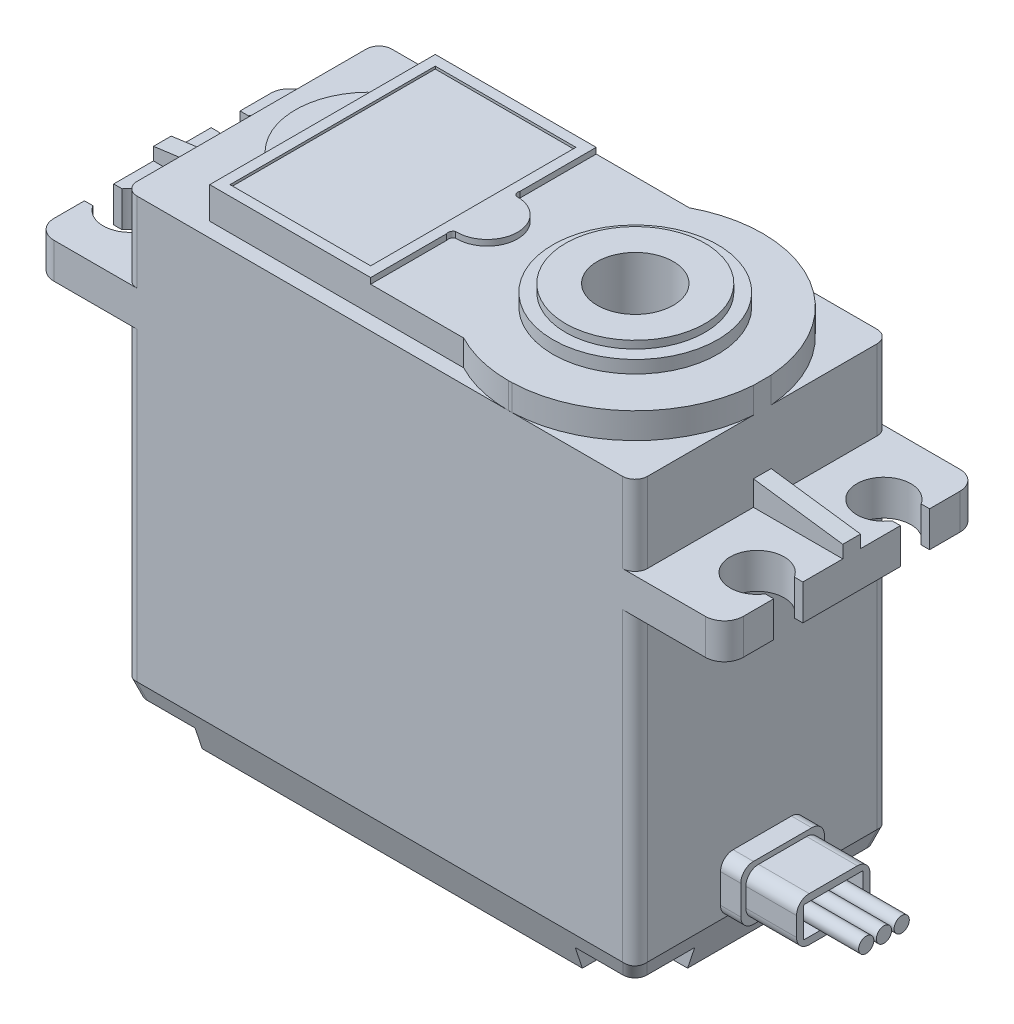
from build123d import *

# Parameters (mm, degrees)
Y_KSEKLIK_EKSTR_ZYON1_DEPTH      = 20.1
Y_KSEKLIK_EKSTR_ZYON2_DEPTH      = 0.7
Y_KSEKLIK_EKSTR_ZYON2_DEPTH_BACK = 0.7
KES_EKSTR_ZYON2_DEPTH            = 50
RADYUS1_R                        = 1.5
RADYUS2_R                        = 1
KES_EKSTR_ZYON4_DEPTH            = 2.5
KES_EKSTR_ZYON6_DEPTH            = 0.4
KES_EKSTR_ZYON7_DEPTH            = 0.46
KES_EKSTR_ZYON8_DEPTH            = 2.5
IZIM10_W                         = 9
IZIM10_H                         = 2.5
KES_EKSTR_ZYON9_DEPTH            = 0.005
IZIM11_W                         = 11.1
IZIM11_H                         = 16.2
KES_EKSTR_ZYON10_DEPTH           = 0.2
IZIM12_R                         = 6.5
IZIM12_R_2                       = 5.5
Y_KSEKLIK_EKSTR_ZYON3_DEPTH      = 1
IZIM13_R                         = 5.5
Y_KSEKLIK_EKSTR_ZYON4_DEPTH      = 1.6
IZIM14_R                         = 3
KES_EKSTR_ZYON11_DEPTH           = 10
KES_EKSTR_ZYON12_DEPTH           = 50
KES_EKSTR_ZYON13_DEPTH           = 50
RADYUS3_R                        = 1
KES_EKSTR_ZYON14_DEPTH           = 1.7
IZIM20_R                         = 1.35
KES_EKSTR_ZYON15_DEPTH           = 32
IZIM21_W                         = 6.6
IZIM21_H                         = 4.3
Y_KSEKLIK_EKSTR_ZYON5_DEPTH      = 1.6
RADYUS4_R                        = 1
IZIM22_W                         = 5.8
IZIM22_H                         = 3.5
Y_KSEKLIK_EKSTR_ZYON6_DEPTH      = 4
RADYUS6_R                        = 1
IZIM23_W                         = 4.7
IZIM23_H                         = 2.4
KES_EKSTR_ZYON17_DEPTH           = 4
RADYUS7_R                        = 0.1
IZIM24_R                         = 0.6
Y_KSEKLIK_EKSTR_ZYON7_DEPTH      = 8


with BuildPart() as part:
    # Çizim1 → Yükseklik-Ekstrüzyon1 (new body)
    with BuildSketch(Plane.XY):
        Polygon((-48.759292093, -35.698320222), (-8.459292093, -35.698320222), (-8.459292093, -8.598320222), (-1.409292093, -8.598320222), (-1.409292093, -5.798320222), (-8.459292093, -5.798320222), (-8.459292093, 3.001679778), (-48.759292093, 3.001679778), (-48.759292093, -5.798320222), (-55.809292093, -5.798320222), (-55.809292093, -8.598320222), (-48.759292093, -8.598320222), align=None)
    extrude(amount=Y_KSEKLIK_EKSTR_ZYON1_DEPTH)

    # Çizim3 → Yükseklik-Ekstrüzyon2 (add, two sides)
    with BuildSketch(Plane.XY.offset(10.05)) as y_kseklik_ekstr_zyon2_sk:
        Polygon((-55.809292093, -5.798320222), (-48.759292093, -5.798320222), (-48.759292093, -3.848320222), (-55.809292093, -4.798320222), align=None)
        Polygon((-8.459292093, -5.798320222), (-1.409292093, -5.798320222), (-1.409292093, -4.798320222), (-8.459292093, -3.848320222), align=None)
    extrude(amount=Y_KSEKLIK_EKSTR_ZYON2_DEPTH)
    extrude(y_kseklik_ekstr_zyon2_sk.sketch, amount=-Y_KSEKLIK_EKSTR_ZYON2_DEPTH_BACK)

    # Çizim4 → Kes-Ekstrüzyon2 (cut)
    with BuildSketch(Plane(origin=(0, 3.001679778, 0), x_dir=(1, 0, 0), z_dir=(0, 1, 0))):
        with BuildLine():
            Line((-55.809292093, -16.2), (-55.146292093, -16.2))
            ThreePointArc((-55.146292093, -16.2), (-51.225748416, -15.04637383), (-55.146292093, -13.892747659))
            Line((-55.146292093, -13.892747659), (-55.809292093, -13.892747659))
            Line((-55.809292093, -13.892747659), (-55.809292093, -16.2))
        make_face()
        with BuildLine():
            Line((-55.809292093, -3.916330706), (-55.146292093, -3.916330706))
            ThreePointArc((-55.146292093, -3.916330706), (-51.218205988, -5.058165353), (-55.146292093, -6.2))
            Line((-55.146292093, -6.2), (-55.809292093, -6.2))
            Line((-55.809292093, -6.2), (-55.809292093, -3.916330706))
        make_face()
        with BuildLine():
            Line((-1.409292093, -6.2), (-2.072292093, -6.2))
            ThreePointArc((-2.072292093, -6.2), (-5.995166879, -5.05), (-2.072292093, -3.9))
            Line((-2.072292093, -3.9), (-1.409292093, -3.9))
            Line((-1.409292093, -3.9), (-1.409292093, -6.2))
        make_face()
        with BuildLine():
            Line((-1.409292093, -13.902170696), (-2.072292093, -13.902170696))
            ThreePointArc((-2.072292093, -13.902170696), (-5.995862588, -15.051085348), (-2.072292093, -16.2))
            Line((-2.072292093, -16.2), (-1.409292093, -16.2))
            Line((-1.409292093, -16.2), (-1.409292093, -13.902170696))
        make_face()
    extrude(amount=-KES_EKSTR_ZYON2_DEPTH, mode=Mode.SUBTRACT)

    # Radyus1
    radyus1_edges = [part.edges().sort_by_distance(p)[0] for p in [
        (-1.409292093, -7.198320222, 20.1),
        (-55.809292093, -7.198320222, 0),
        (-1.409292093, -7.198320222, 0),
        (-55.809292093, -7.198320222, 20.1),
    ]]
    fillet(radyus1_edges, radius=RADYUS1_R)

    # Radyus2
    radyus2_edges = [part.edges().sort_by_distance(p)[0] for p in [
        (-48.759292093, -22.148320222, 0),
        (-48.759292093, -1.398320222, 0),
        (-8.459292093, -1.398320222, 0),
        (-8.459292093, -22.148320222, 0),
        (-8.459292093, -1.398320222, 20.1),
        (-48.759292093, -1.398320222, 20.1),
        (-48.759292093, -22.148320222, 20.1),
        (-8.459292093, -22.148320222, 20.1),
    ]]
    fillet(radyus2_edges, radius=RADYUS2_R)

    # Çizim5 → Kes-Ekstrüzyon4 (cut)
    with BuildSketch(Plane(origin=(0, 3.001679778, 0), x_dir=(1, 0, 0), z_dir=(0, 1, 0))):
        with BuildLine():
            ThreePointArc((-23.127535874, -1.15), (-20.863195169, -0.291734273), (-18.459292093, 0))
            Line((-18.459292093, 0), (-47.759292093, 0))
            ThreePointArc((-47.759292093, 0), (-48.466398874, -0.292893219), (-48.759292093, -1))
            Line((-48.759292093, -1), (-48.759292093, -19.1))
            ThreePointArc((-48.759292093, -19.1), (-48.466398874, -19.807106781), (-47.759292093, -20.1))
            Line((-47.759292093, -20.1), (-18.459292093, -20.1))
            ThreePointArc((-18.459292093, -20.1), (-20.863195169, -19.808265727), (-23.127535874, -18.95))
            Line((-23.127535874, -18.95), (-43.170310905, -18.95))
            Line((-43.170310905, -18.95), (-43.170310905, -14.54))
            ThreePointArc((-43.170310905, -14.54), (-45.305060631, -10.05), (-43.170310905, -5.56))
            Line((-43.170310905, -5.56), (-43.170310905, -1.15))
            Line((-43.170310905, -1.15), (-23.127535874, -1.15))
        make_face()
    extrude(amount=-KES_EKSTR_ZYON4_DEPTH, mode=Mode.SUBTRACT)

    # Çizim7 → Kes-Ekstrüzyon6 (cut)
    with BuildSketch(Plane(origin=(0, 3.001679778, 0), x_dir=(1, 0, 0), z_dir=(0, 1, 0))):
        with BuildLine():
            Line((-43.170310905, -5.56), (-43.170310905, -14.54))
            ThreePointArc((-43.170310905, -14.54), (-45.305060631, -10.05), (-43.170310905, -5.56))
        make_face()
    extrude(amount=-KES_EKSTR_ZYON6_DEPTH, mode=Mode.SUBTRACT)

    # Çizim8 → Kes-Ekstrüzyon7 (cut)
    with BuildSketch(Plane(origin=(0, 3.001679778, 0), x_dir=(1, 0, 0), z_dir=(0, 1, 0))):
        with BuildLine():
            Line((-30.470310905, -1.15), (-23.127535874, -1.15))
            ThreePointArc((-23.127535874, -1.15), (-8.409292093, -10.05), (-23.127535874, -18.95))
            Line((-23.127535874, -18.95), (-30.470310905, -18.95))
            Line((-30.470310905, -18.95), (-30.470310905, -12.945))
            ThreePointArc((-30.470310905, -12.945), (-30.47115449, -12.654263301), (-30.266169104, -12.448084904))
            ThreePointArc((-30.266169104, -12.448084904), (-27.770310905, -10.05), (-30.266169104, -7.651915096))
            ThreePointArc((-30.266169104, -7.651915096), (-30.47115449, -7.445736699), (-30.470310905, -7.155))
            Line((-30.470310905, -7.155), (-30.470310905, -1.15))
        make_face()
    extrude(amount=-KES_EKSTR_ZYON7_DEPTH, mode=Mode.SUBTRACT)

    # Çizim9 → Kes-Ekstrüzyon8 (cut)
    with BuildSketch(Plane(origin=(0, 3.001679778, 0), x_dir=(1, 0, 0), z_dir=(0, 1, 0))):
        with BuildLine():
            Line((-18.459292093, 0), (-8.459292093, 0))
            Line((-8.459292093, 0), (-8.459292093, -9.35))
            ThreePointArc((-8.459292093, -9.35), (-11.621052025, -2.708967842), (-18.459292093, 0))
        make_face()
        with BuildLine():
            Line((-8.459292093, -20.099934818), (-8.459292093, -10.749934818))
            ThreePointArc((-8.459292093, -10.749934818), (-11.621052025, -17.390966976), (-18.459292093, -20.099934818))
            Line((-18.459292093, -20.099934818), (-8.459292093, -20.099934818))
        make_face()
    extrude(amount=-KES_EKSTR_ZYON8_DEPTH, mode=Mode.SUBTRACT)

    # Çizim10 → Kes-Ekstrüzyon9 (cut)
    with BuildSketch(Plane.XY.offset(20.1)):
        with Locations((-13.959292093, 1.751679778)):
            Rectangle(IZIM10_W, IZIM10_H)
    extrude(amount=-KES_EKSTR_ZYON9_DEPTH, mode=Mode.SUBTRACT)

    # Çizim11 → Kes-Ekstrüzyon10 (cut)
    with BuildSketch(Plane(origin=(0, 3.001679778, 0), x_dir=(1, 0, 0), z_dir=(0, 1, 0))):
        with Locations((-36.820310905, -10.05)):
            Rectangle(IZIM11_W, IZIM11_H)
    extrude(amount=-KES_EKSTR_ZYON10_DEPTH, mode=Mode.SUBTRACT)

    # Çizim12 → Yükseklik-Ekstrüzyon3 (add)
    with BuildSketch(Plane(origin=(0, 2.541679778, 0), x_dir=(1, 0, 0), z_dir=(0, 1, 0))):
        with Locations((-18.48488662, -10.049967409)):
            Circle(IZIM12_R)
        with Locations((-18.48488662, -10.049967409)):
            Circle(IZIM12_R_2, mode=Mode.SUBTRACT)
    extrude(amount=Y_KSEKLIK_EKSTR_ZYON3_DEPTH)

    # Çizim13 → Yükseklik-Ekstrüzyon4 (add)
    with BuildSketch(Plane(origin=(0, 2.541679778, 0), x_dir=(1, 0, 0), z_dir=(0, 1, 0))):
        with Locations((-18.48488662, -10.049967409)):
            Circle(IZIM13_R)
    extrude(amount=Y_KSEKLIK_EKSTR_ZYON4_DEPTH)

    # Çizim14 → Kes-Ekstrüzyon11 (cut)
    with BuildSketch(Plane(origin=(0, 4.141679778, 0), x_dir=(1, 0, 0), z_dir=(0, 1, 0))):
        with Locations((-18.48488662, -10.049967409)):
            Circle(IZIM14_R)
    extrude(amount=-KES_EKSTR_ZYON11_DEPTH, mode=Mode.SUBTRACT)

    # Çizim15 → Kes-Ekstrüzyon12 (cut)
    with BuildSketch(Plane.ZY.offset(48.759292093)):
        Polygon((20.1, -35.698320222), (20.1, -32.698320222), (19.1, -35.698320222), align=None)
        Polygon((0, -35.698320222), (1, -35.698320222), (0, -32.698320222), align=None)
    extrude(amount=-KES_EKSTR_ZYON12_DEPTH, mode=Mode.SUBTRACT)

    # Çizim17 → Kes-Ekstrüzyon13 (cut)
    with BuildSketch(Plane.XY.offset(20.1)):
        Polygon((-48.759292093, -32.698320222), (-48.759292093, -35.698320222), (-47.759292093, -35.698320222), align=None)
        Polygon((-8.459292093, -35.698320222), (-9.459292093, -35.698320222), (-8.459292093, -32.698320222), align=None)
    extrude(amount=-KES_EKSTR_ZYON13_DEPTH, mode=Mode.SUBTRACT)

    # Radyus3
    radyus3_edges = [part.edges().sort_by_distance(p)[0] for p in [
        (-9.105738702, -34.63766005, 0.646446609),
        (-48.112845483, -34.63766005, 0.646446609),
        (-9.105738702, -34.63766005, 19.453553391),
        (-48.112845483, -34.63766005, 19.453553391),
    ]]
    fillet(radyus3_edges, radius=RADYUS3_R)

    # Çizim18 → Kes-Ekstrüzyon14 (cut)
    with BuildSketch(Plane.XZ.offset(35.698320222)):
        with BuildLine():
            Line((-48.759292093, 20.1), (-43.609292093, 20.1))
            Line((-43.609292093, 20.1), (-43.609292093, 17.6))
            ThreePointArc((-43.609292093, 17.6), (-44.385459123, 15.72616703), (-46.259292093, 14.95))
            Line((-46.259292093, 14.95), (-48.759292093, 14.95))
            Line((-48.759292093, 14.95), (-48.759292093, 20.1))
        make_face()
        with BuildLine():
            Line((-48.759292093, 5.15), (-46.259292093, 5.15))
            ThreePointArc((-46.259292093, 5.15), (-44.385459123, 4.37383297), (-43.609292093, 2.5))
            Line((-43.609292093, 2.5), (-43.609292093, 0))
            Line((-43.609292093, 0), (-48.759292093, 0))
            Line((-48.759292093, 0), (-48.759292093, 5.15))
        make_face()
        with BuildLine():
            Line((-8.459292093, 14.95), (-10.959292093, 14.95))
            ThreePointArc((-10.959292093, 14.95), (-12.833125063, 15.72616703), (-13.609292093, 17.6))
            Line((-13.609292093, 17.6), (-13.609292093, 20.1))
            Line((-13.609292093, 20.1), (-8.459292093, 20.1))
            Line((-8.459292093, 20.1), (-8.459292093, 14.95))
        make_face()
        with BuildLine():
            Line((-8.459292093, 0), (-13.609292093, 0))
            Line((-13.609292093, 0), (-13.609292093, 2.5))
            ThreePointArc((-13.609292093, 2.5), (-12.833125063, 4.37383297), (-10.959292093, 5.15))
            Line((-10.959292093, 5.15), (-8.459292093, 5.15))
            Line((-8.459292093, 5.15), (-8.459292093, 0))
        make_face()
    extrude(amount=-KES_EKSTR_ZYON14_DEPTH, mode=Mode.SUBTRACT)

    # Çizim20 → Kes-Ekstrüzyon15 (cut)
    with BuildSketch(Plane(origin=(0, -33.998320222, 0), x_dir=(-1, 0, 0), z_dir=(0, -1, 0))):
        with Locations((46.259292093, -2.5)):
            Circle(IZIM20_R)
        with Locations((10.959292093, -17.6)):
            Circle(IZIM20_R)
        with Locations((10.959292093, -2.5)):
            Circle(IZIM20_R)
        with Locations((46.259292093, -17.6)):
            Circle(IZIM20_R)
    extrude(amount=-KES_EKSTR_ZYON15_DEPTH, mode=Mode.SUBTRACT)

    # Çizim21 → Yükseklik-Ekstrüzyon5 (add)
    with BuildSketch(Plane(origin=(-8.459292093, 0, 0), x_dir=(0, 0, -1), z_dir=(1, 0, 0))):
        with Locations((-10.05, -30.548320222)):
            Rectangle(IZIM21_W, IZIM21_H)
    extrude(amount=Y_KSEKLIK_EKSTR_ZYON5_DEPTH)

    # Radyus4
    radyus4_edges = [part.edges().sort_by_distance(p)[0] for p in [
        (-7.659292093, -28.398320222, 13.35),
        (-7.659292093, -32.698320222, 13.35),
        (-7.659292093, -32.698320222, 6.75),
        (-7.659292093, -28.398320222, 6.75),
    ]]
    fillet(radyus4_edges, radius=RADYUS4_R)

    # Çizim22 → Yükseklik-Ekstrüzyon6 (add)
    with BuildSketch(Plane(origin=(-6.859292093, 0, 0), x_dir=(0, 0, -1), z_dir=(1, 0, 0))):
        with Locations((-10.05, -30.548320222)):
            Rectangle(IZIM22_W, IZIM22_H)
    extrude(amount=Y_KSEKLIK_EKSTR_ZYON6_DEPTH)

    # Radyus6
    radyus6_edges = [part.edges().sort_by_distance(p)[0] for p in [
        (-4.859292093, -28.798320222, 12.95),
        (-4.859292093, -32.298320222, 12.95),
        (-4.859292093, -32.298320222, 7.15),
        (-4.859292093, -28.798320222, 7.15),
    ]]
    fillet(radyus6_edges, radius=RADYUS6_R)

    # Çizim23 → Kes-Ekstrüzyon17 (cut)
    with BuildSketch(Plane(origin=(-2.859292093, 0, 0), x_dir=(0, 0, -1), z_dir=(1, 0, 0))):
        with Locations((-10.05, -30.548320222)):
            Rectangle(IZIM23_W, IZIM23_H)
    extrude(amount=-KES_EKSTR_ZYON17_DEPTH, mode=Mode.SUBTRACT)

    # Radyus7
    radyus7_edges = [part.edges().sort_by_distance(p)[0] for p in [
        (-4.859292093, -31.748320222, 7.7),
        (-4.859292093, -29.348320222, 7.7),
        (-4.859292093, -29.348320222, 12.4),
        (-4.859292093, -31.748320222, 12.4),
    ]]
    fillet(radyus7_edges, radius=RADYUS7_R)

    # Çizim24 → Yükseklik-Ekstrüzyon7 (add)
    with BuildSketch(Plane(origin=(-6.859292093, 0, 0), x_dir=(0, 0, -1), z_dir=(1, 0, 0))):
        with Locations((-11.45, -30.548320222)):
            Circle(IZIM24_R)
        with Locations((-10.05, -30.548320222)):
            Circle(IZIM24_R)
        with Locations((-8.65, -30.548320222)):
            Circle(IZIM24_R)
    extrude(amount=Y_KSEKLIK_EKSTR_ZYON7_DEPTH)


solid = part.part
